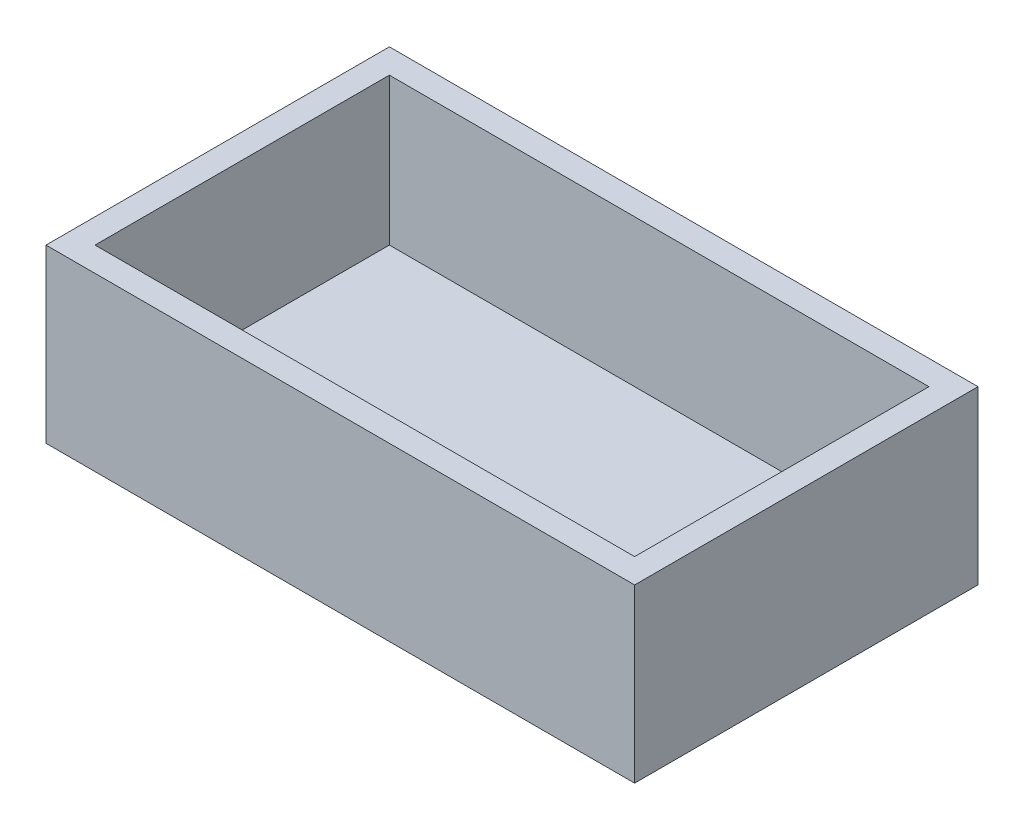
from build123d import *

# Parameters (mm, degrees)
SKETCH4_W           = 152.4
SKETCH4_H           = 88.9
BOSS_EXTRUDE2_DEPTH = 44.45
SKETCH6_W           = 139.7
SKETCH6_H           = 76.2
CUT_EXTRUDE1_DEPTH  = 38.1


with BuildPart() as part:
    # Sketch4 → Boss-Extrude2 (new body)
    with BuildSketch(Plane(origin=(0, 0, 0), x_dir=(1, 0, 0), z_dir=(0, 1, 0))):
        with Locations((76.2, 44.45)):
            Rectangle(SKETCH4_W, SKETCH4_H)
    extrude(amount=BOSS_EXTRUDE2_DEPTH)

    # Sketch6 → Cut-Extrude1 (cut)
    with BuildSketch(Plane(origin=(0, 44.45, 0), x_dir=(1, 0, 0), z_dir=(0, 1, 0))):
        with Locations((76.2, 44.45)):
            Rectangle(SKETCH6_W, SKETCH6_H)
    extrude(amount=-CUT_EXTRUDE1_DEPTH, mode=Mode.SUBTRACT)


solid = part.part
